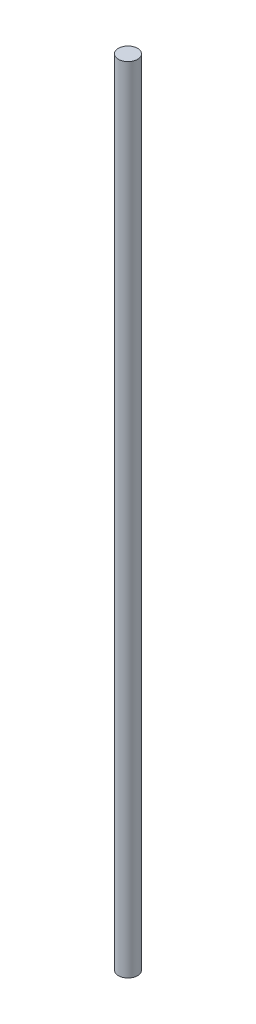
from build123d import *

# Parameters (mm, degrees)
SKETCH2_R           = 3.4
BOSS_EXTRUDE1_DEPTH = 282


with BuildPart() as part:
    # Sketch2 → Boss-Extrude1 (new body)
    with BuildSketch(Plane(origin=(0, 0, 0), x_dir=(1, 0, 0), z_dir=(0, 1, 0))):
        Circle(SKETCH2_R)
    extrude(amount=BOSS_EXTRUDE1_DEPTH)


solid = part.part
